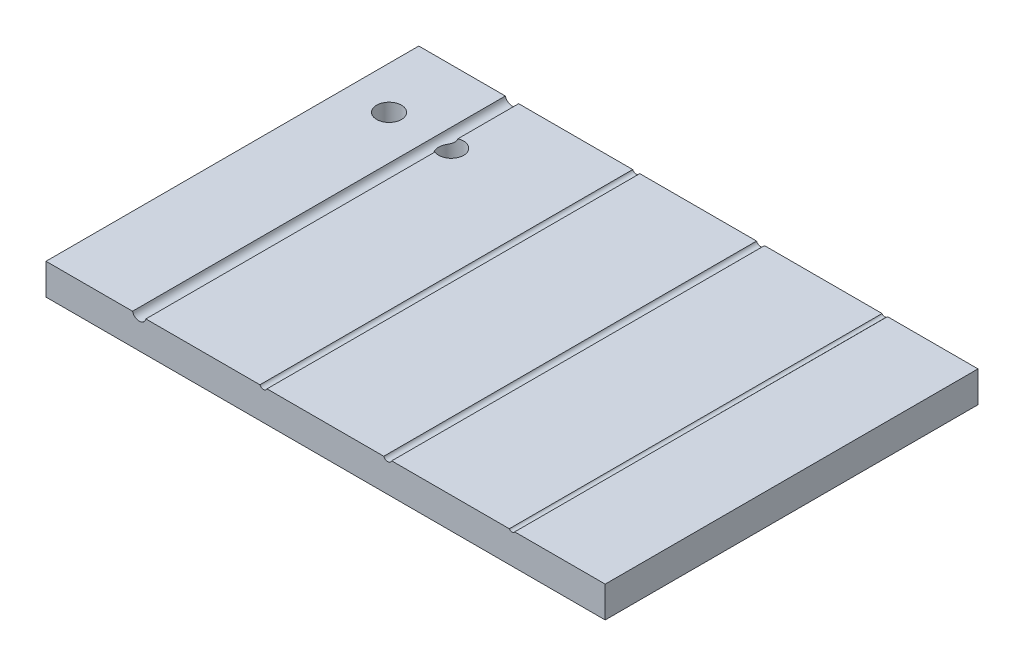
from build123d import *

# Parameters (mm, degrees)
SKETCH1_W           = 90
SKETCH1_H           = 60
BOSS_EXTRUDE1_DEPTH = 5
SKETCH2_R           = 1.1
SKETCH2_R_2         = 0.62
SKETCH2_R_3         = 0.6858
SKETCH2_R_4         = 0.5
CUT_EXTRUDE1_DEPTH  = 61
SKETCH3_R           = 2
CUT_EXTRUDE2_DEPTH  = 6


with BuildPart() as part:
    # Sketch1 → Boss-Extrude1 (new body)
    with BuildSketch(Plane(origin=(0, 0, 0), x_dir=(1, 0, 0), z_dir=(0, 1, 0))):
        with Locations((-15.754716981, 62.075471698)):
            Rectangle(SKETCH1_W, SKETCH1_H)
    extrude(amount=BOSS_EXTRUDE1_DEPTH)

    # Sketch2 → Cut-Extrude1 (cut, through all)
    with BuildSketch(Plane.XY.offset(-32.075471698)):
        with Locations((-45.754716981, 5.25)):
            Circle(SKETCH2_R)
        with Locations((-25.754716981, 5.25)):
            Circle(SKETCH2_R_2)
        with Locations((-5.754716981, 5.25)):
            Circle(SKETCH2_R_3)
        with Locations((14.245283019, 5.25)):
            Circle(SKETCH2_R_4)
    extrude(amount=-CUT_EXTRUDE1_DEPTH, mode=Mode.SUBTRACT)

    # Sketch3 → Cut-Extrude2 (cut, through all)
    with BuildSketch(Plane(origin=(0, 5, 0), x_dir=(1, 0, 0), z_dir=(0, 1, 0))):
        with Locations((-53.907444579, 80.442311963)):
            Circle(SKETCH3_R)
        with Locations((-43.907444579, 80.442311963)):
            Circle(SKETCH3_R)
    extrude(amount=-CUT_EXTRUDE2_DEPTH, mode=Mode.SUBTRACT)


solid = part.part
